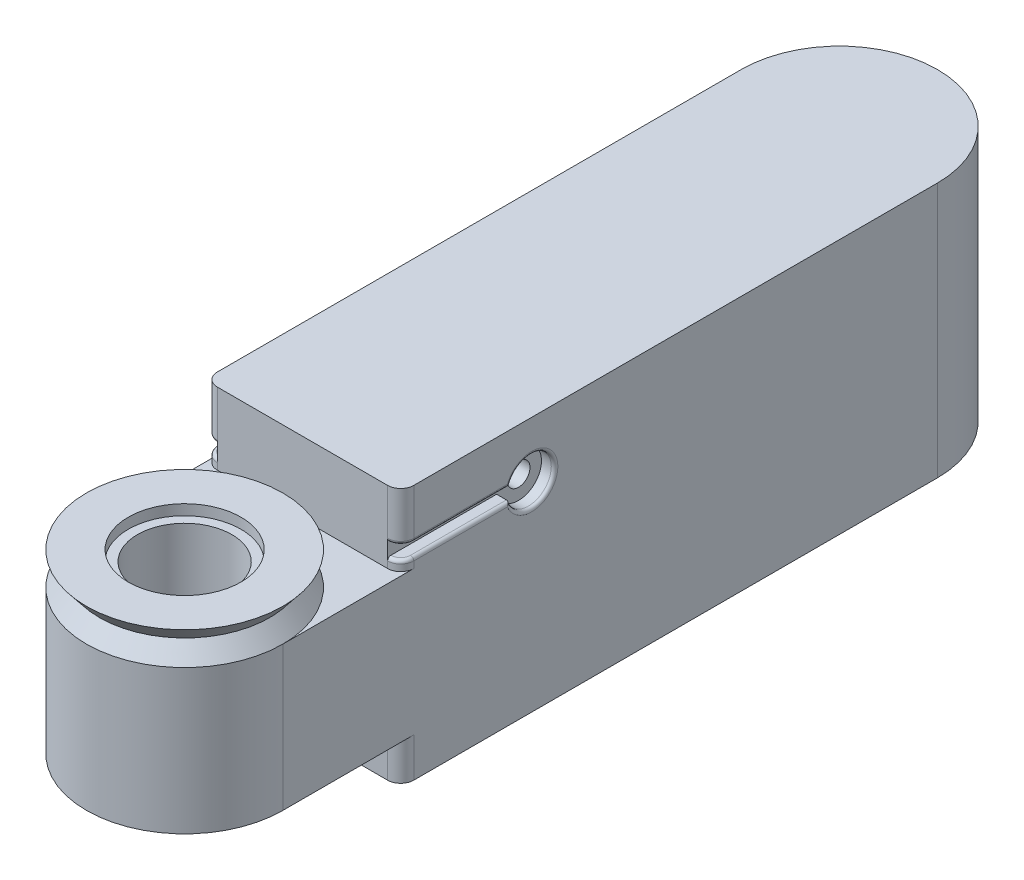
from build123d import *

# Parameters (mm, degrees)
EXTRUDE_1_DEPTH      = 11
EXTRUDE_2_DEPTH      = 3
EXTRUDE_2_DEPTH_BACK = 16.5
FILLET_1_R           = 1
SKETCH_6_W           = 1
SKETCH_6_H           = 1
CUT_EXTRUDE_3_DEPTH  = 10
CUT_EXTRUDE_4_REACH  = 63.673
SKETCH_8_R           = 0.5
SKETCH_9_R           = 1.5
CUT_EXTRUDE_5_DEPTH  = 1
SKETCH_10_R          = 1.75
CUT_EXTRUDE_6_DEPTH  = 1
FILLET_2_R           = 0.25
SKETCH_11_R          = 2
CUT_EXTRUDE_7_DEPTH  = 13.5
SKETCH_13_R          = 3.6
CUT_EXTRUDE_8_DEPTH  = 13.5
SKETCH_14_R          = 4.3
CUT_EXTRUDE_9_DEPTH  = 0.8
CUT_EXTRUDE_START    = -0.8
SKETCH_15_R          = 4.3
CUT_EXTRUDE_10_DEPTH = 0.8
SKETCH_16_R          = 0.875
CUT_EXTRUDE_11_DEPTH = 13


with BuildPart() as part:
    # 스케치1 → 보스-돌출1 (new body)
    with BuildSketch(Plane(origin=(0, 0, 0), x_dir=(1, 0, 0), z_dir=(0, 1, 0))):
        with BuildLine():
            Line((-7.5, 0), (-7.5, 50))
            ThreePointArc((-7.5, 50), (0, 57.5), (7.5, 50))
            Line((7.5, 50), (7.5, 0))
            ThreePointArc((7.5, 0), (0, -7.5), (-7.5, 0))
        make_face()
    extrude(amount=EXTRUDE_1_DEPTH)

    # 스케치2 → 회전1 (revolve)
    with BuildSketch(Plane.XY):
        Polygon((-7.5, 11), (0, 11), (0, 13.5), (-7.5, 13.5), (-6.5, 12.25), align=None)
    revolve(axis=Axis((0, 13.5, 0), (0, -1, 0)))

    # 스케치3 → 보스-돌출2 (add, two sides: drawn at the far end of the back side and taken through both)
    with BuildSketch(Plane.XZ.offset(-EXTRUDE_2_DEPTH_BACK)):
        with BuildLine():
            Line((-7.5, -50), (-7.5, -9))
            Line((-7.5, -9), (7.5, -9))
            Line((7.5, -9), (7.5, -50))
            ThreePointArc((7.5, -50), (0, -57.5), (-7.5, -50))
        make_face()
    extrude(amount=EXTRUDE_2_DEPTH + EXTRUDE_2_DEPTH_BACK)

    # 필렛1
    fillet_1_edges = [part.edges().sort_by_distance(p)[0] for p in [
        (7.5, -1.5, -9),
        (-7.5, -1.5, -9),
        (7.5, 13.75, -9),
        (-7.5, 13.75, -9),
    ]]
    fillet(fillet_1_edges, radius=FILLET_1_R)

    # 스케치6 → 컷-돌출3 (cut)
    with BuildSketch(Plane.XY.offset(-9)):
        with Locations((-7, 12.25)):
            Rectangle(SKETCH_6_W, SKETCH_6_H)
        with Locations((7, 12.25)):
            Rectangle(SKETCH_6_W, SKETCH_6_H)
    extrude(amount=-CUT_EXTRUDE_3_DEPTH, mode=Mode.SUBTRACT)

    # 컷-돌출4: up to this face of the body (flat: up to its plane)
    cut_extrude_4_end = Plane(part.part.faces().sort_by_distance((7.5, 6.537741203, -27.036889898))[0])
    # 스케치8 → 컷-돌출4 (cut, up to the picked face)
    with BuildSketch(Plane.ZY.offset(7.5), mode=Mode.PRIVATE) as cut_extrude_4_sk1:
        with Locations(Location((-19, 12.25, 0), (0, 0, 270))):
            Circle(SKETCH_8_R)
    cut_extrude_4_tool1 = split(extrude(cut_extrude_4_sk1.sketch, amount=-CUT_EXTRUDE_4_REACH, mode=Mode.PRIVATE), bisect_by=cut_extrude_4_end, keep=Keep.BOTH, mode=Mode.PRIVATE)
    add(cut_extrude_4_tool1.solids().sort_by(Axis((-7.5, 12.25, -19), (1, 0, 0)))[0], mode=Mode.SUBTRACT)

    # 스케치9 → 컷-돌출5 (cut)
    with BuildSketch(Plane.ZY.offset(7.5)):
        with Locations((-19, 12.25)):
            Circle(SKETCH_9_R)
    extrude(amount=-CUT_EXTRUDE_5_DEPTH, mode=Mode.SUBTRACT)

    # 스케치10 → 컷-돌출6 (cut)
    with BuildSketch(Plane(origin=(7.5, 0, 0), x_dir=(0, 0, -1), z_dir=(1, 0, 0))):
        with Locations((19, 12.25)):
            Circle(SKETCH_10_R)
    extrude(amount=-CUT_EXTRUDE_6_DEPTH, mode=Mode.SUBTRACT)

    # 필렛2
    fillet_2_edges = [part.edges().sort_by_distance(p)[0] for p in [
        (7.207106781, 12.75, -9.292893219),
        (7.207106781, 11.75, -9.292893219),
        (-7.5, 11.75, -13.792893219),
        (-7.5, 12.75, -13.792893219),
        (-7.5, 12.25, -20.5),
        (7.5, 12.75, -13.661474508),
        (7.5, 11.75, -13.661474508),
        (7.5, 12.25, -20.75),
        (-7.207106781, 11.75, -9.292893219),
        (-7.207106781, 12.75, -9.292893219),
    ]]
    fillet(fillet_2_edges, radius=FILLET_2_R)

    # 스케치11 → 컷-돌출7 (cut)
    with BuildSketch(Plane(origin=(0, 13.5, 0), x_dir=(1, 0, 0), z_dir=(0, 1, 0))):
        with Locations(Location((0, 0, 0), (0, 0, 270))):
            Circle(SKETCH_11_R)
    extrude(amount=-CUT_EXTRUDE_7_DEPTH, mode=Mode.SUBTRACT)

    # 스케치13 → 컷-돌출8 (cut)
    with BuildSketch(Plane(origin=(0, 13.5, 0), x_dir=(1, 0, 0), z_dir=(0, 1, 0))):
        with Locations(Location((0, 0, 0), (0, 0, 270))):
            Circle(SKETCH_13_R)
    extrude(amount=-CUT_EXTRUDE_8_DEPTH, mode=Mode.SUBTRACT)

    # 스케치14 → 컷-돌출9 (cut)
    with BuildSketch(Plane(origin=(0, 13.5, 0), x_dir=(1, 0, 0), z_dir=(0, 1, 0))):
        with Locations(Location((0, 0, 0), (0, 0, 270))):
            Circle(SKETCH_14_R)
    extrude(amount=-CUT_EXTRUDE_9_DEPTH, mode=Mode.SUBTRACT)

    # 스케치15 → 컷-돌출10 (cut)
    with BuildSketch(Plane(origin=(0, 0, 0), x_dir=(-1, 0, 0), z_dir=(0, -1, 0)).offset(CUT_EXTRUDE_START)):
        with Locations(Location((0, 0, 0), (0, 0, 270))):
            Circle(SKETCH_15_R)
    extrude(amount=CUT_EXTRUDE_10_DEPTH, mode=Mode.SUBTRACT)

    # 스케치16 → 컷-돌출11 (cut)
    with BuildSketch(Plane(origin=(6.5, 0, 0), x_dir=(0, 0, -1), z_dir=(1, 0, 0))):
        with Locations((19, 12.25)):
            Circle(SKETCH_16_R)
    extrude(amount=-CUT_EXTRUDE_11_DEPTH, mode=Mode.SUBTRACT)


solid = part.part
